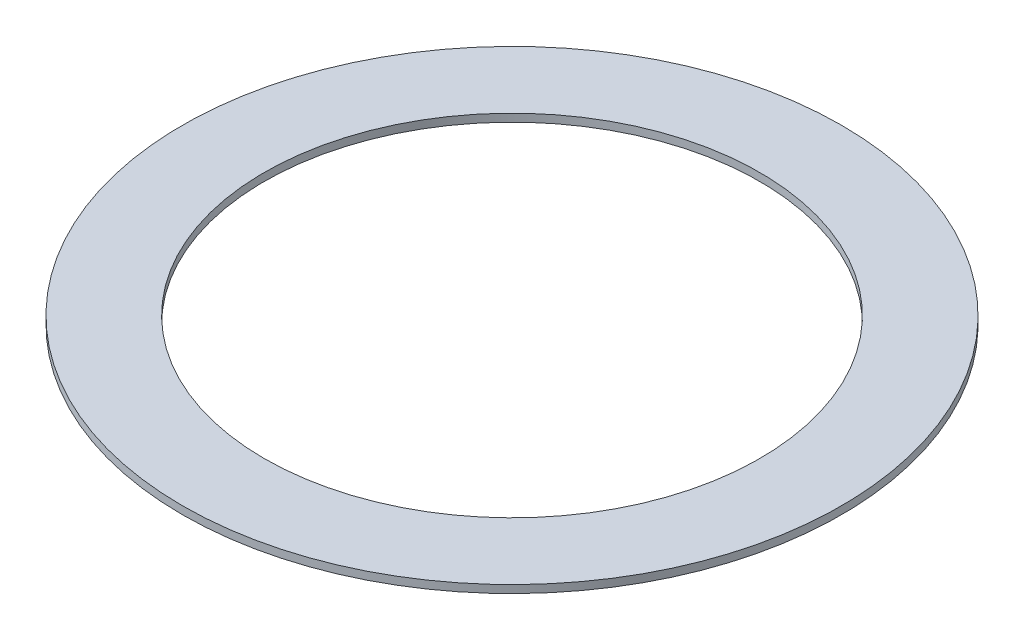
from build123d import *

# Parameters (mm, degrees)
SKETCH1_R           = 101.346
SKETCH1_R_2         = 76.2
BOSS_EXTRUDE1_DEPTH = 2.4


with BuildPart() as part:
    # Sketch1 → Boss-Extrude1 (new body)
    with BuildSketch(Plane(origin=(0, 0, 0), x_dir=(1, 0, 0), z_dir=(0, 1, 0))):
        Circle(SKETCH1_R)
        Circle(SKETCH1_R_2, mode=Mode.SUBTRACT)
    extrude(amount=BOSS_EXTRUDE1_DEPTH)


solid = part.part
